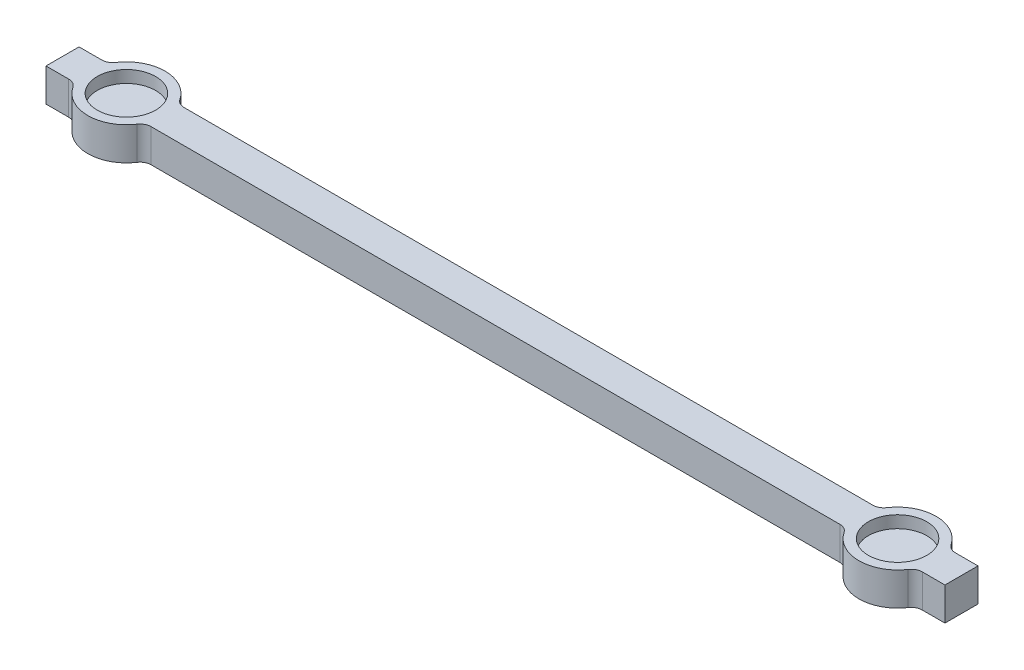
from build123d import *

# Parameters (mm, degrees)
SKETCH1_R          = 3.5
SKETCH1_W          = 81.6
SKETCH1_H          = 3
BASE_SHAPE_DEPTH   = 3
SKETCH2_R          = 2.65
MAGNET_HOLES_DEPTH = 1.1
MILLING_FILLETS_R  = 1


with BuildPart() as part:
    # Sketch1 → Base shape (new body)
    with BuildSketch(Plane(origin=(0, 0, 0), x_dir=(1, 0, 0), z_dir=(0, 1, 0))):
        with Locations((-35, 0)):
            Circle(SKETCH1_R)
        with Locations((35, 0)):
            Circle(SKETCH1_R)
        Rectangle(SKETCH1_W, SKETCH1_H)
    extrude(amount=BASE_SHAPE_DEPTH)

    # Sketch2 → Magnet holes (cut)
    with BuildSketch(Plane(origin=(0, 3, 0), x_dir=(1, 0, 0), z_dir=(0, 1, 0))):
        with Locations((-35, 0)):
            Circle(SKETCH2_R)
        with Locations((35, 0)):
            Circle(SKETCH2_R)
    extrude(amount=-MAGNET_HOLES_DEPTH, mode=Mode.SUBTRACT)

    # Milling fillets
    milling_fillets_edges = [part.edges().sort_by_distance(p)[0] for p in [
        (-38.16227766, 1.5, -1.5),
        (31.83772234, 1.5, -1.5),
        (38.16227766, 1.5, -1.5),
        (31.83772234, 1.5, 1.5),
        (38.16227766, 1.5, 1.5),
        (-31.83772234, 1.5, 1.5),
        (-38.16227766, 1.5, 1.5),
        (-31.83772234, 1.5, -1.5),
    ]]
    fillet(milling_fillets_edges, radius=MILLING_FILLETS_R)


solid = part.part
